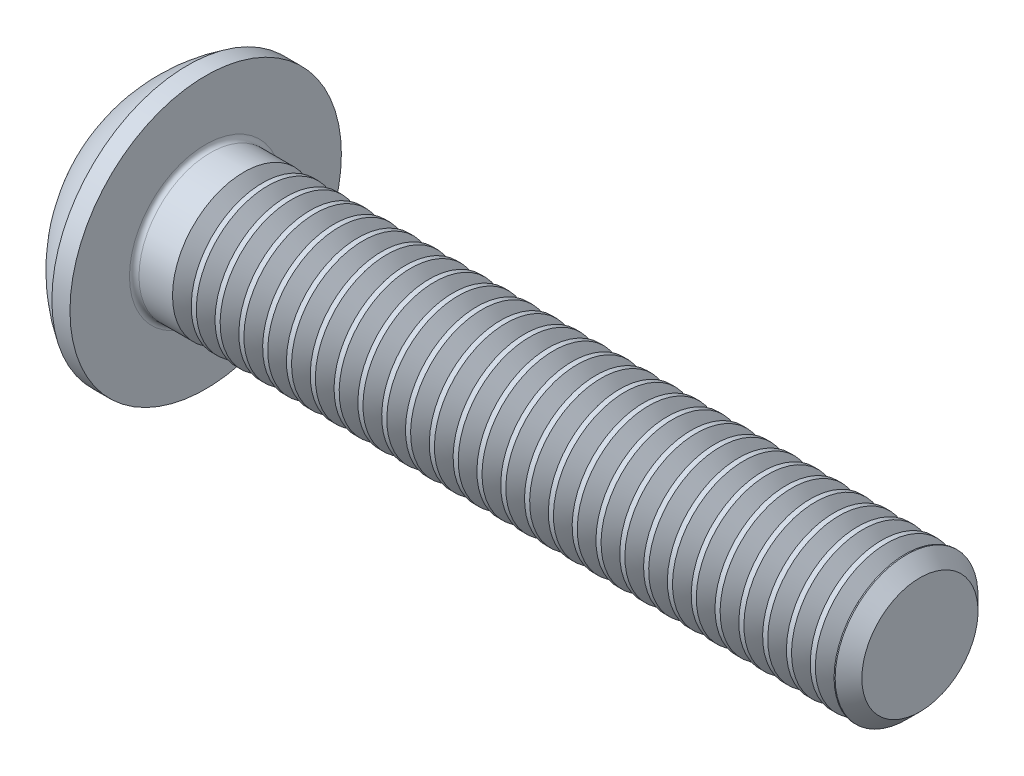
from build123d import *

# Parameters (mm, degrees)
FILLET1_R       = 0.1
HEX_2_DEPTH     = 1.04
THDSCHPAT_COUNT = 28
THDSCHPAT_PITCH = 0.5


with BuildPart() as part:
    # BodySke → BaseBody (revolve)
    with BuildSketch(Plane.XY):
        with BuildLine():
            Line((16.65, 0), (16.65, 1.2195))
            Line((16.65, 1.2195), (16.3695, 1.5))
            Line((16.3695, 1.5), (1.65, 1.5))
            Line((1.65, 1.5), (1.65, 2.85))
            Line((1.65, 2.85), (1.27, 2.85))
            ThreePointArc((1.27, 2.85), (0.53140404, 2.229827628), (0, 1.425))
            Line((0, 1.425), (0, 0))
            Line((0, 0), (16.65, 0))
        make_face()
    revolve(axis=Axis((0, 0, 0), (1, 0, 0)))

    # Fillet1
    fillet1_edges = [part.edges().sort_by_distance(p)[0] for p in [
        (1.65, -1.5, 0),
    ]]
    fillet(fillet1_edges, radius=FILLET1_R)

    # Sketch2 → PreBroach (revolve, cut)
    with BuildSketch(Plane.XY):
        Polygon((0, 1), (1.04, 1), (1.617350269, 0), (0, 0), align=None)
    revolve(axis=Axis((0, 0, 0), (1, 0, 0)), mode=Mode.SUBTRACT)

    # Sketch3 → Hex 2 (cut)
    with BuildSketch(Plane(origin=(0, 0, 0), x_dir=(0, 0, -1), z_dir=(1, 0, 0))):
        Polygon((-1, -0.577350269), (-1, 0.577350269), (0, 1.154700538), (1, 0.577350269), (1, -0.577350269), (0, -1.154700538), align=None)
    extrude(amount=HEX_2_DEPTH, mode=Mode.SUBTRACT)

    # ThdSchSke → ThreadSchematic (revolve, cut)
    with BuildSketch(Plane.XY):
        Polygon((2.65, -1.2195), (2.453591786, -1.5), (2.453591786, -1.875), (2.846408214, -1.875), (2.846408214, -1.5), align=None)
    threadschematic = revolve(axis=Axis((-3.175, 0, 0), (1, 0, 0)), mode=Mode.SUBTRACT)

    # ThdSchPat: ThreadSchematic ×28
    with Locations(*[(i * THDSCHPAT_PITCH, 0, 0) for i in range(1, THDSCHPAT_COUNT)]):
        add(threadschematic, mode=Mode.SUBTRACT)


solid = part.part
